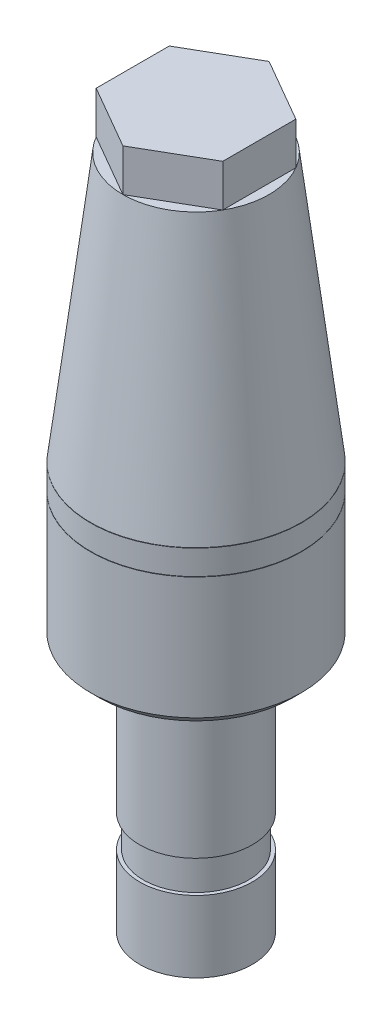
from build123d import *

# Parameters (mm, degrees)
SKETCH5_W           = 7.5
SKETCH5_H           = 1.7526
BOSS_EXTRUDE1_START = 25.5
BOSS_EXTRUDE1_DEPTH = 3


with BuildPart() as part:
    # Sketch5 → Revolve1 (revolve)
    with BuildSketch(Plane.XY):
        Polygon((-4, -25.5), (-4, -20.42), (-3.746, -20.42), (-3.746, -18.134), (-4, -18.134), (-4, -7.65), (-6.865, -7.65), (-7.5, -7.015), (-7.5, 1.6591), (0, 1.6591), (0, -7.65), (-2.857, -7.65), (-2.857, -25.5), align=None)
        Polygon((-7.5, 3.4625), (-5.196152423, 22.5), (0, 22.5), (0, 3.4625), align=None)
        with Locations((-3.75, 2.5608)):
            Rectangle(SKETCH5_W, SKETCH5_H)
    revolve(axis=Axis((0, 22.5, 0), (0, -1, 0)))

    # Sketch6 → Cut-Revolve1 (revolve, cut)
    with BuildSketch(Plane.XY):
        Polygon((-2.857, -7.65), (-6.23, -4.277), (-6.23, 3.4625), (-4.079843108, 21.23), (0, 21.23), (0, -7.65), align=None)
    revolve(axis=Axis((0, 21.23, 0), (0, -1, 0)), mode=Mode.SUBTRACT)


with BuildPart() as body_2:
    # Sketch3 → Boss-Extrude1 (new body)
    with BuildSketch(Plane(origin=(0, 0, 0), x_dir=(1, 0, 0), z_dir=(0, 1, 0)).offset(BOSS_EXTRUDE1_START)):
        Polygon((0, 5.196152423), (-4.5, 2.598076211), (-4.5, -2.598076211), (0, -5.196152423), (4.5, -2.598076211), (4.5, 2.598076211), align=None)
    extrude(amount=-BOSS_EXTRUDE1_DEPTH)


solid = Compound([part.part, body_2.part])
